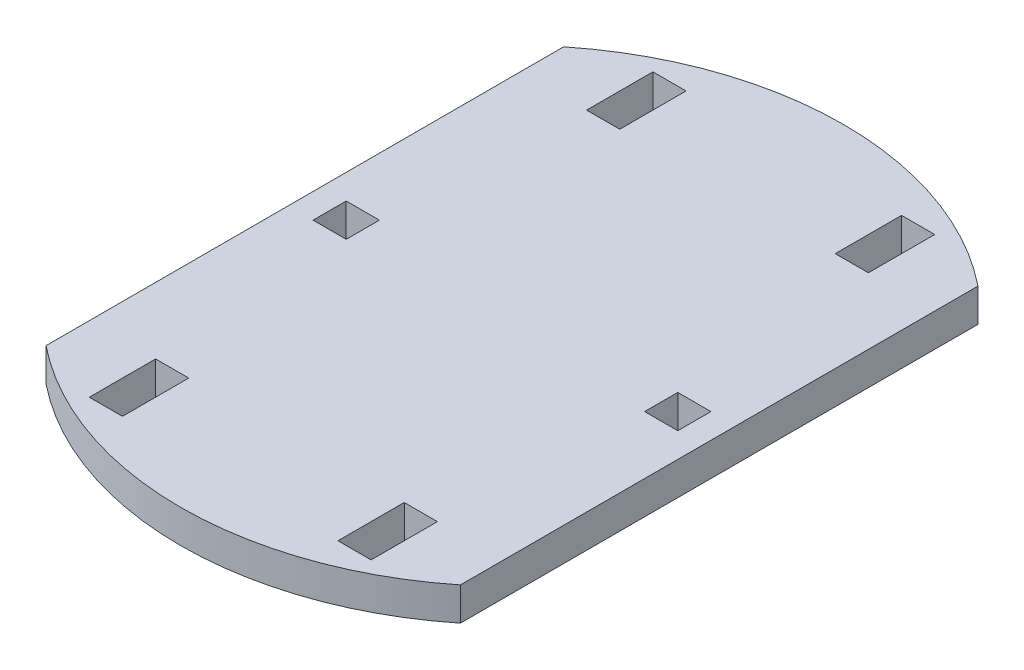
from build123d import *

# Parameters (mm, degrees)
SKETCH1_W           = 4
SKETCH1_H           = 8
SKETCH1_H_2         = 4
BOSS_EXTRUDE1_DEPTH = 4


with BuildPart() as part:
    # Sketch1 → Boss-Extrude1 (new body)
    with BuildSketch(Plane(origin=(0, 0, 0), x_dir=(1, 0, 0), z_dir=(0, 1, 0))):
        with BuildLine():
            ThreePointArc((25, 31.224989992), (0, 40), (-25, 31.224989992))
            Line((-25, 31.224989992), (-25, -31.224989992))
            ThreePointArc((-25, -31.224989992), (0, -40), (25, -31.224989992))
            Line((25, -31.224989992), (25, 31.224989992))
        make_face()
        with Locations((-15, -30)):
            Rectangle(SKETCH1_W, SKETCH1_H, mode=Mode.SUBTRACT)
        with Locations((15, -30)):
            Rectangle(SKETCH1_W, SKETCH1_H, mode=Mode.SUBTRACT)
        with Locations((-20, 0)):
            Rectangle(SKETCH1_W, SKETCH1_H_2, mode=Mode.SUBTRACT)
        with Locations((-15, 30)):
            Rectangle(SKETCH1_W, SKETCH1_H, mode=Mode.SUBTRACT)
        with Locations((20, 0)):
            Rectangle(SKETCH1_W, SKETCH1_H_2, mode=Mode.SUBTRACT)
        with Locations((15, 30)):
            Rectangle(SKETCH1_W, SKETCH1_H, mode=Mode.SUBTRACT)
    extrude(amount=BOSS_EXTRUDE1_DEPTH)


solid = part.part
